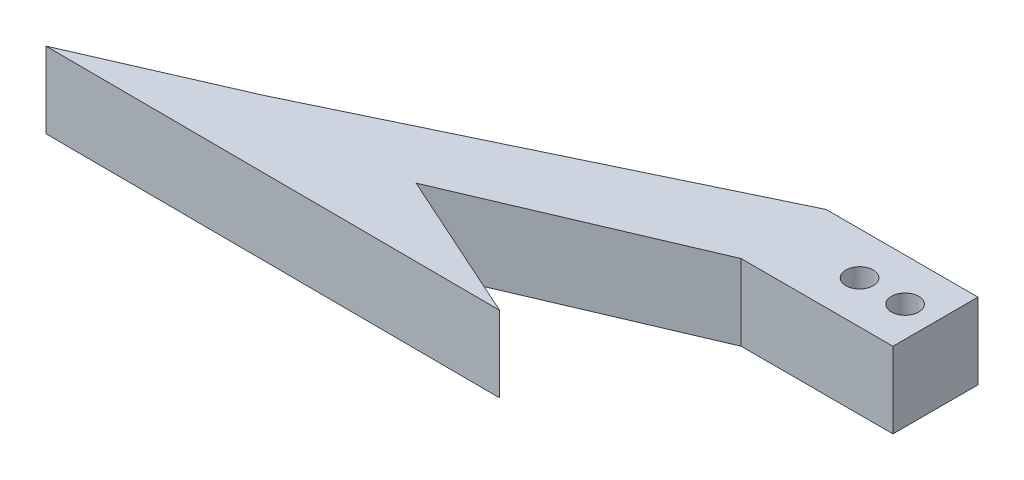
from build123d import *

# Parameters (mm, degrees)
SKETCH2_W           = 12.7
SKETCH2_H           = 7.112
SKETCH2_R           = 1.143
BOSS_EXTRUDE1_DEPTH = 6.35
BOSS_EXTRUDE2_DEPTH = 6.35


with BuildPart() as part:
    # Sketch2 → Boss-Extrude1 (new body)
    with BuildSketch(Plane(origin=(0, 0, 0), x_dir=(1, 0, 0), z_dir=(0, 1, 0))):
        Polygon((-12.7, -3.556), (-31.75, -11.684), (-44.45, -11.684), (-12.7, 3.556), align=None)
        with Locations((-6.35, 0)):
            Rectangle(SKETCH2_W, SKETCH2_H)
        with Locations((-6.35, 0)):
            Circle(SKETCH2_R, mode=Mode.SUBTRACT)
        with Locations((-2.54, 0)):
            Circle(SKETCH2_R, mode=Mode.SUBTRACT)
    extrude(amount=BOSS_EXTRUDE1_DEPTH)

    # Sketch3 → Boss-Extrude2 (add)
    with BuildSketch(Plane(origin=(0, 0, 0), x_dir=(1, 0, 0), z_dir=(0, 1, 0))):
        Polygon((-44.45, -11.684), (-57.15, -17.231593434), (-19.05, -17.3978371), (-31.75, -11.684), align=None)
    extrude(amount=BOSS_EXTRUDE2_DEPTH)


solid = part.part
